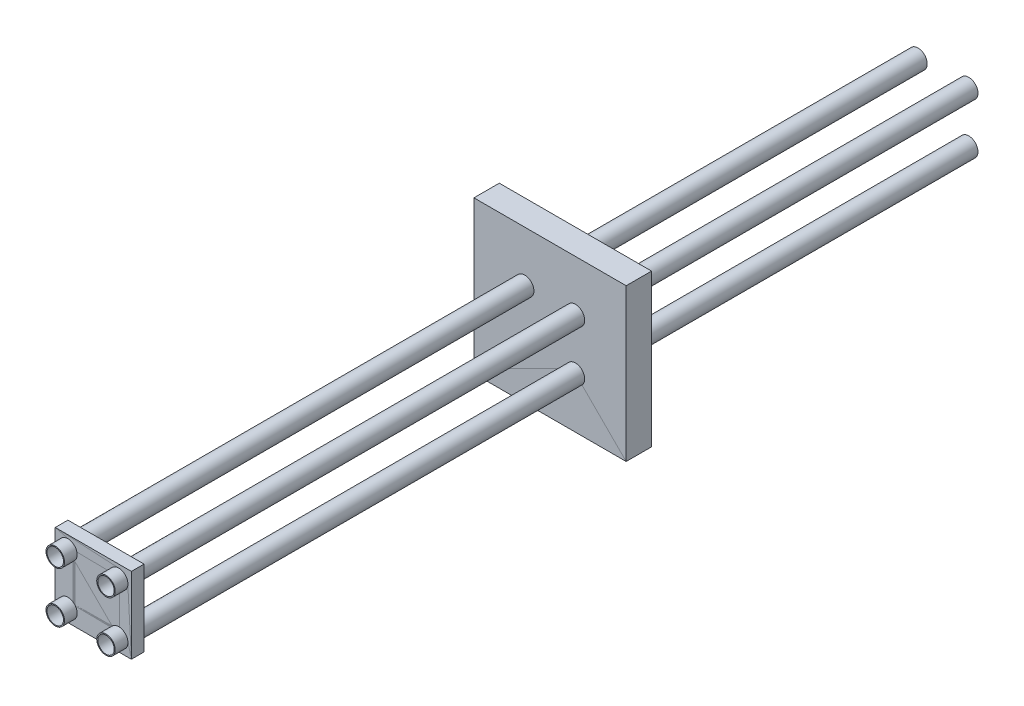
from build123d import *

# Parameters (mm, degrees)
SKETCH1_W            = 3000
SKETCH1_H            = 3000
BOSS_EXTRUDE1_DEPTH  = 500
SHELL1_T             = 10
EXTRUDE_THIN4_START  = -33000
SKETCH6_R            = 365
SKETCH6_R_2          = 325
EXTRUDE_THIN4_DEPTH  = 34000
LPATTERN1_COUNT      = 2
LPATTERN1_PITCH      = 2000
LPATTERN1_COUNT_DIR2 = 2
LPATTERN1_PITCH_DIR2 = 2000
SKETCH7_2_W          = 6000
SKETCH7_2_H          = 6000
BOSS_EXTRUDE3_DEPTH  = 1000


with BuildPart() as part:
    # Sketch1 → Boss-Extrude1 (new body)
    with BuildSketch(Plane.XY):
        Rectangle(SKETCH1_W, SKETCH1_H)
    extrude(amount=BOSS_EXTRUDE1_DEPTH)

    # Shell1 (no face opened: a closed hollow body)
    add(offset(amount=-SHELL1_T, mode=Mode.PRIVATE), mode=Mode.SUBTRACT)

    # Sketch6 → Extrude-Thin4 (add)
    with BuildSketch(Plane.XY.offset(EXTRUDE_THIN4_START)):
        with Locations((-1000, 1000)):
            Circle(SKETCH6_R)
        with Locations((-1000, 1000)):
            Circle(SKETCH6_R_2, mode=Mode.SUBTRACT)
    extrude_thin4 = extrude(amount=EXTRUDE_THIN4_DEPTH)

    # LPattern1: Extrude-Thin4 2 × 2
    with Locations(*[(i * LPATTERN1_PITCH, -j * LPATTERN1_PITCH_DIR2, 0) for i in range(LPATTERN1_COUNT) for j in range(LPATTERN1_COUNT_DIR2) if (i, j) != (0, 0)]):
        add(extrude_thin4)

    # Sketch7_2 → Boss-Extrude3 (add)
    with BuildSketch(Plane.XY.offset(-17500)):
        Rectangle(SKETCH7_2_W, SKETCH7_2_H)
    extrude(amount=-BOSS_EXTRUDE3_DEPTH)


solid = part.part
